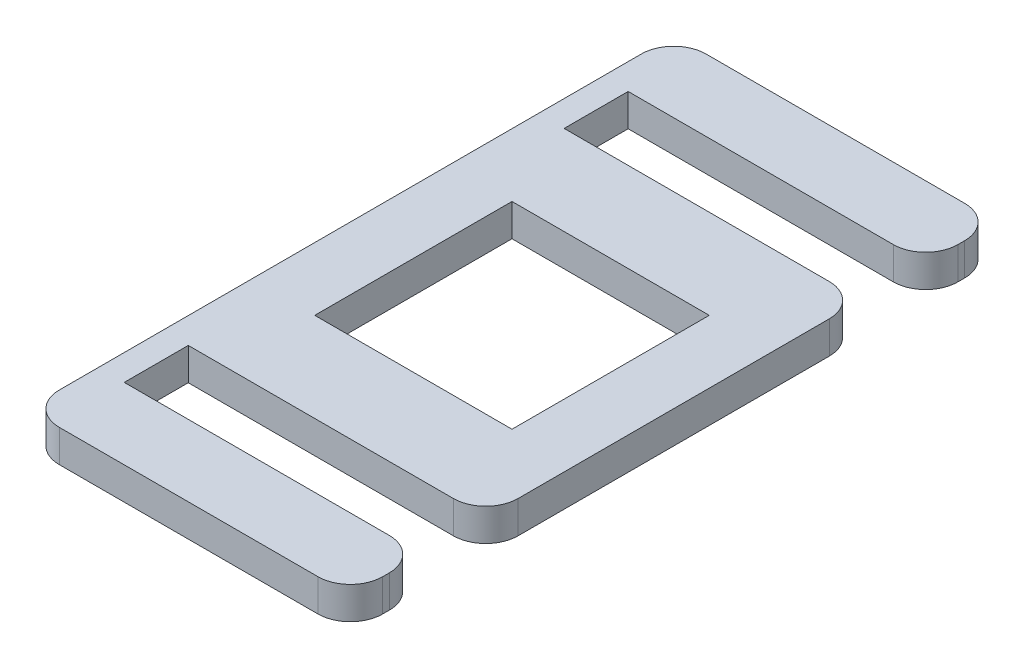
from build123d import *

# Parameters (mm, degrees)
SKETCH1_W           = 50
SKETCH1_H           = 100
BOSS_EXTRUDE1_DEPTH = 5
SKETCH2_W           = 52.895350152
SKETCH2_H           = 9.9
CUT_EXTRUDE1_DEPTH  = 6
FILLET1_R           = 5
SKETCH3_W           = 30.5
SKETCH3_H           = 30.5
CUT_EXTRUDE2_DEPTH  = 6


with BuildPart() as part:
    # Sketch1 → Boss-Extrude1 (new body)
    with BuildSketch(Plane(origin=(0, 0, 0), x_dir=(1, 0, 0), z_dir=(0, 1, 0))):
        Rectangle(SKETCH1_W, SKETCH1_H)
    extrude(amount=BOSS_EXTRUDE1_DEPTH)

    # Sketch2 → Cut-Extrude1 (cut, through all)
    with BuildSketch(Plane(origin=(0, 5, 0), x_dir=(1, 0, 0), z_dir=(0, 1, 0))):
        with Locations((5.447675076, -34.01)):
            Rectangle(SKETCH2_W, SKETCH2_H)
    cut_extrude1 = extrude(amount=-CUT_EXTRUDE1_DEPTH, mode=Mode.SUBTRACT)

    # Mirror1: Cut-Extrude1 across plane
    add(cut_extrude1.mirror(Plane.XY), mode=Mode.SUBTRACT)

    # Fillet1
    fillet1_edges = [part.edges().sort_by_distance(p)[0] for p in [
        (25, 2.5, 38.96),
        (25, 2.5, 29.06),
        (25, 2.5, -29.06),
        (25, 2.5, -38.96),
        (25, 2.5, 50),
        (-25, 2.5, 50),
        (-25, 2.5, -50),
        (25, 2.5, -50),
    ]]
    fillet(fillet1_edges, radius=FILLET1_R)

    # Sketch3 → Cut-Extrude2 (cut, through all)
    with BuildSketch(Plane(origin=(0, 5, 0), x_dir=(1, 0, 0), z_dir=(0, 1, 0))):
        Rectangle(SKETCH3_W, SKETCH3_H)
    extrude(amount=-CUT_EXTRUDE2_DEPTH, mode=Mode.SUBTRACT)


solid = part.part
